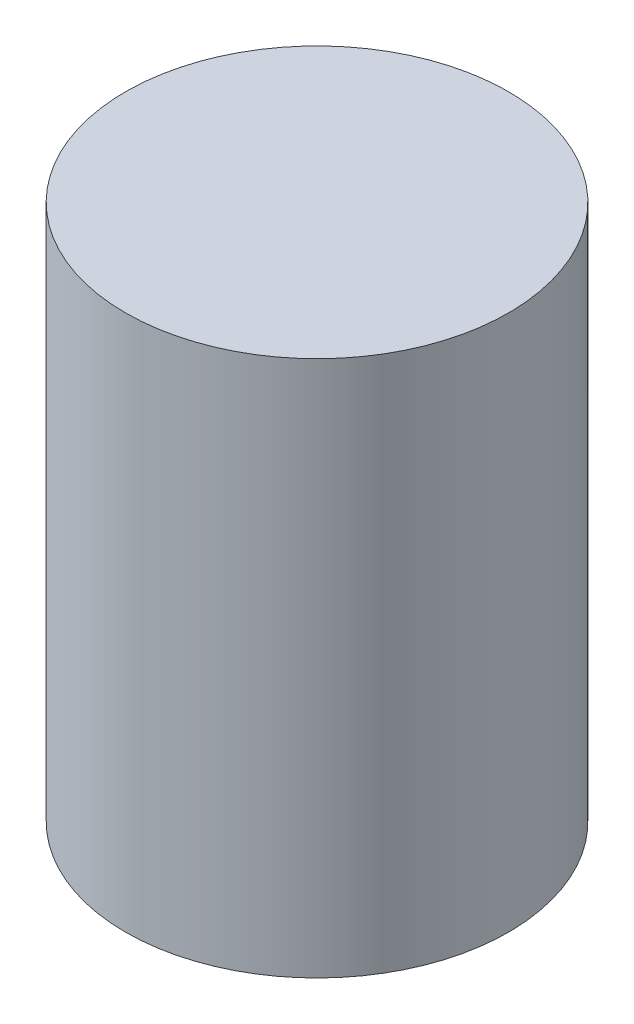
from build123d import *

# Parameters (mm, degrees)
SKETCH1_R           = 50
BOSS_EXTRUDE1_DEPTH = 140
SKETCH3_R           = 10
CUT_EXTRUDE2_DEPTH  = 120
SKETCH4_R           = 30
CUT_EXTRUDE3_DEPTH  = 40


with BuildPart() as part:
    # Sketch1 → Boss-Extrude1 (new body)
    with BuildSketch(Plane(origin=(0, 0, 0), x_dir=(1, 0, 0), z_dir=(0, 1, 0))):
        Circle(SKETCH1_R)
    extrude(amount=BOSS_EXTRUDE1_DEPTH)

    # Sketch3 → Cut-Extrude2 (cut)
    with BuildSketch(Plane.XZ):
        Circle(SKETCH3_R)
    extrude(amount=-CUT_EXTRUDE2_DEPTH, mode=Mode.SUBTRACT)

    # Sketch4 → Cut-Extrude3 (cut)
    with BuildSketch(Plane.XZ):
        Circle(SKETCH4_R)
    extrude(amount=-CUT_EXTRUDE3_DEPTH, mode=Mode.SUBTRACT)


solid = part.part
